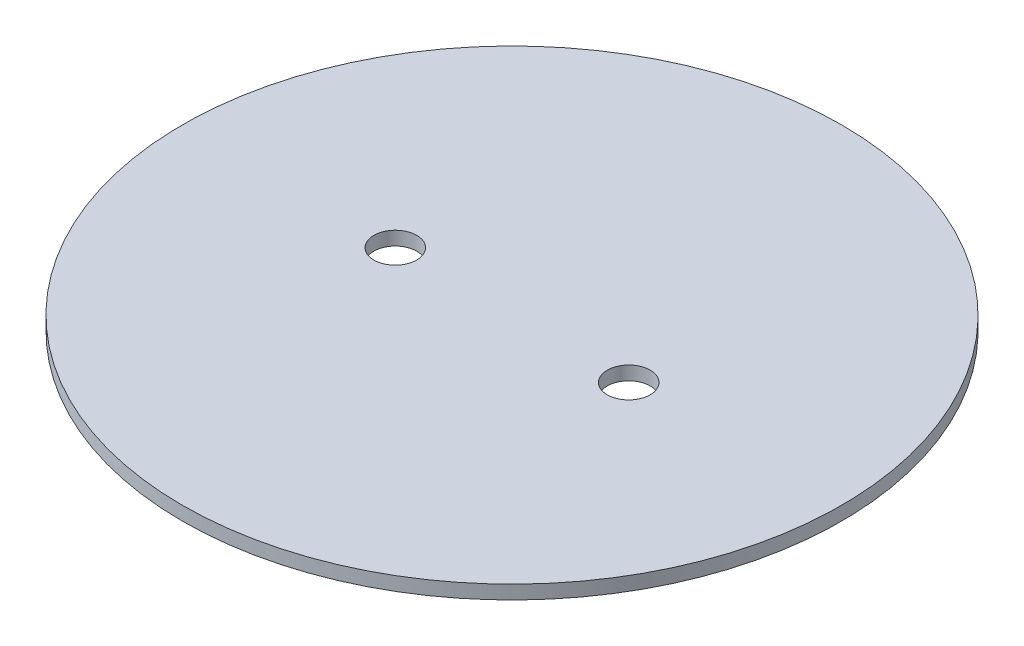
from build123d import *

# Parameters (mm, degrees)
SKETCH1_R           = 76.2
SKETCH1_R_2         = 4.953
BOSS_EXTRUDE1_DEPTH = 3.175


with BuildPart() as part:
    # Sketch1 → Boss-Extrude1 (new body)
    with BuildSketch(Plane(origin=(0, 0, 0), x_dir=(1, 0, 0), z_dir=(0, 1, 0))):
        Circle(SKETCH1_R)
        with Locations((26.9875, 0)):
            Circle(SKETCH1_R_2, mode=Mode.SUBTRACT)
        with Locations((-26.9875, 0)):
            Circle(SKETCH1_R_2, mode=Mode.SUBTRACT)
    extrude(amount=BOSS_EXTRUDE1_DEPTH)


solid = part.part
